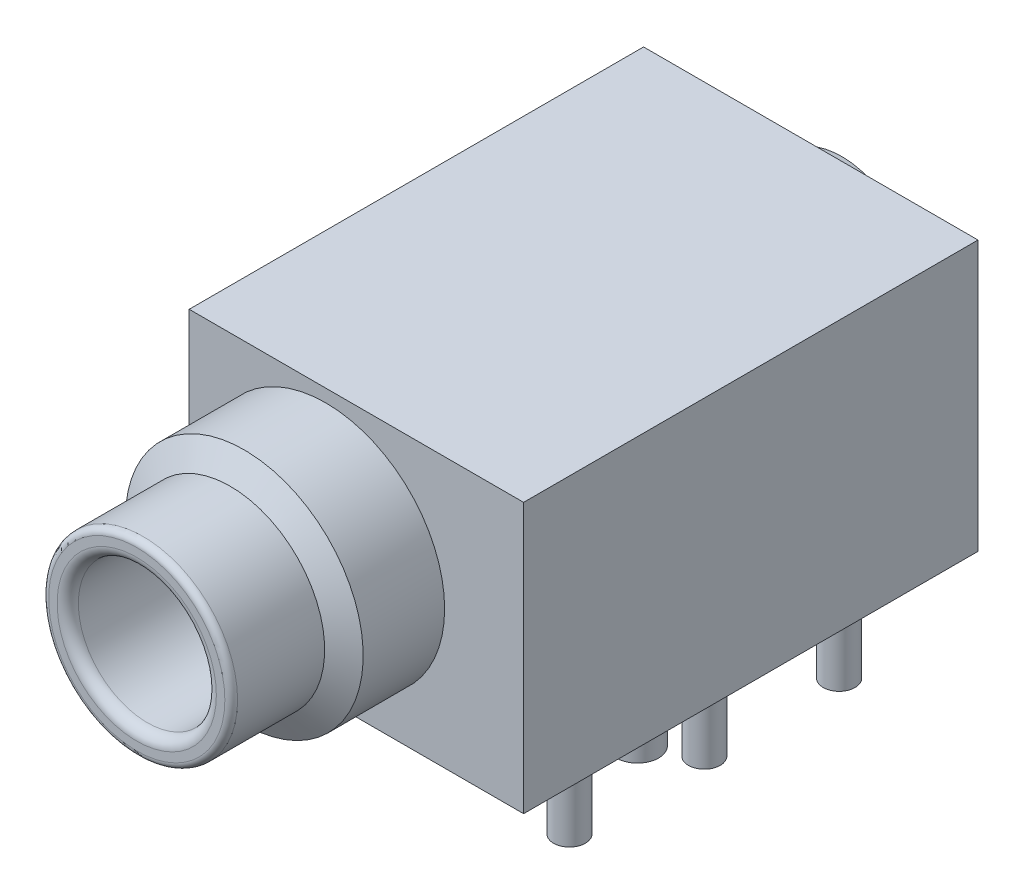
from build123d import *

# Parameters (mm, degrees)
SKETCH1_W                      = 15.75
SKETCH1_H                      = 21.4
BOSS_EXTRUDE1_DEPTH            = 12.7
SKETCH3_W                      = 0.75
SKETCH3_H                      = 4
SKETCH4_W                      = 0.75
SKETCH4_H                      = 4
SKETCH5_W                      = 0.75
SKETCH5_H                      = 4
SKETCH6_W                      = 0.75
SKETCH6_H                      = 4
SKETCH7_W                      = 0.75
SKETCH7_H                      = 4
SKETCH8_W                      = 0.75
SKETCH8_H                      = 4
SKETCH9_W                      = 1.5
SKETCH9_H                      = 2
SKETCH10_W                     = 1
SKETCH10_H                     = 2
SKETCH11_W                     = 1
SKETCH11_H                     = 2
F_6_5_6_5_DIAMETER_HOLE1_D     = 6.5
F_6_5_6_5_DIAMETER_HOLE1_DEPTH = 30.123611625
F_6_5_6_5_DIAMETER_HOLE1_TIP   = 1.876388375
FILLET1_R                      = 0.3
FILLET2_R                      = 0.5


with BuildPart() as part:
    # Sketch1 → Boss-Extrude1 (new body)
    with BuildSketch(Plane.XZ):
        with Locations((1.445, -10.7)):
            Rectangle(SKETCH1_W, SKETCH1_H)
    extrude(amount=-BOSS_EXTRUDE1_DEPTH)

    # Sketch2 → Revolve1 (revolve)
    with BuildSketch(Plane.XZ.offset(-6.5)):
        Polygon((4.15, -21.4), (0, -21.4), (0, -24.3), (3.5, -24.3), align=None)
    revolve(axis=Axis((0, 6.5, -21.4), (0, 0, -1)))

    # Sketch3 → Contact Pin #1 (revolve)
    with BuildSketch(Plane.XY.offset(-10.6)):
        with Locations((-3.825, -2)):
            Rectangle(SKETCH3_W, SKETCH3_H)
    revolve(axis=Axis((-4.2, 0, -10.6), (0, -1, 0)))

    # Sketch4 → Contact Pin #2 (revolve)
    with BuildSketch(Plane.XY.offset(-10.6)):
        with Locations((7.605, -2)):
            Rectangle(SKETCH4_W, SKETCH4_H)
    revolve(axis=Axis((7.23, 0, -10.6), (0, -1, 0)))

    # Sketch5 → Contact Pin #3 (revolve)
    with BuildSketch(Plane.XY.offset(-16.95)):
        with Locations((-3.825, -2)):
            Rectangle(SKETCH5_W, SKETCH5_H)
    revolve(axis=Axis((-4.2, 0, -16.95), (0, -1, 0)))

    # Sketch6 → Contact Pin #4 (revolve)
    with BuildSketch(Plane.XY.offset(-4.25)):
        with Locations((-3.825, -2)):
            Rectangle(SKETCH6_W, SKETCH6_H)
    revolve(axis=Axis((-4.2, 0, -4.25), (0, -1, 0)))

    # Sketch7 → Contact Pin #5 (revolve)
    with BuildSketch(Plane.XY.offset(-16.95)):
        with Locations((7.605, -2)):
            Rectangle(SKETCH7_W, SKETCH7_H)
    revolve(axis=Axis((7.23, 0, -16.95), (0, -1, 0)))

    # Sketch8 → Contact Pin #6 (revolve)
    with BuildSketch(Plane.XY.offset(-4.25)):
        with Locations((7.605, -2)):
            Rectangle(SKETCH8_W, SKETCH8_H)
    revolve(axis=Axis((7.23, 0, -4.25), (0, -1, 0)))

    # Sketch9 → Revolve8 (revolve)
    with BuildSketch(Plane.XY.offset(-13.8)):
        with Locations((5.85, -1)):
            Rectangle(SKETCH9_W, SKETCH9_H)
    revolve(axis=Axis((5.1, 0, -13.8), (0, -1, 0)))

    # Sketch10 → Revolve9 (revolve)
    with BuildSketch(Plane.XY.offset(-7.45)):
        with Locations((7.73, -1)):
            Rectangle(SKETCH10_W, SKETCH10_H)
    revolve(axis=Axis((7.23, 0, -7.45), (0, -1, 0)))

    # Sketch11 → Revolve10 (revolve)
    with BuildSketch(Plane.XY.offset(-7.45)):
        with Locations((-3.7, -1)):
            Rectangle(SKETCH11_W, SKETCH11_H)
    revolve(axis=Axis((-4.2, 0, -7.45), (0, -1, 0)))

    # Sketch12 → Revolve11 (revolve)
    with BuildSketch(Plane.XZ.offset(-6.5)):
        Polygon((4.45, 8.9), (0, 8.9), (0, 0), (5.6, 0), (5.6, 3.83604719), (4.45, 4.5), align=None)
    revolve(axis=Axis((0, 6.5, 8.9), (0, 0, -1)))

    # Ø6.5 (6.5) Diameter Hole1
    with Locations(Plane.XY.offset(8.9)):
        with Locations((0, 6.5)):
            Hole(F_6_5_6_5_DIAMETER_HOLE1_D / 2, depth=F_6_5_6_5_DIAMETER_HOLE1_DEPTH)
            with Locations((0, 0, -(F_6_5_6_5_DIAMETER_HOLE1_DEPTH + F_6_5_6_5_DIAMETER_HOLE1_TIP / 2))):  # 120° drill point
                Cone(0, F_6_5_6_5_DIAMETER_HOLE1_D / 2, F_6_5_6_5_DIAMETER_HOLE1_TIP, mode=Mode.SUBTRACT)

    # Fillet1
    fillet1_edges = [part.edges().sort_by_distance(p)[0] for p in [
        (-4.45, 6.5, 8.9),
    ]]
    fillet(fillet1_edges, radius=FILLET1_R)

    # Fillet2
    fillet2_edges = [part.edges().sort_by_distance(p)[0] for p in [
        (3.25, 6.5, 8.9),
    ]]
    fillet(fillet2_edges, radius=FILLET2_R)


solid = part.part
